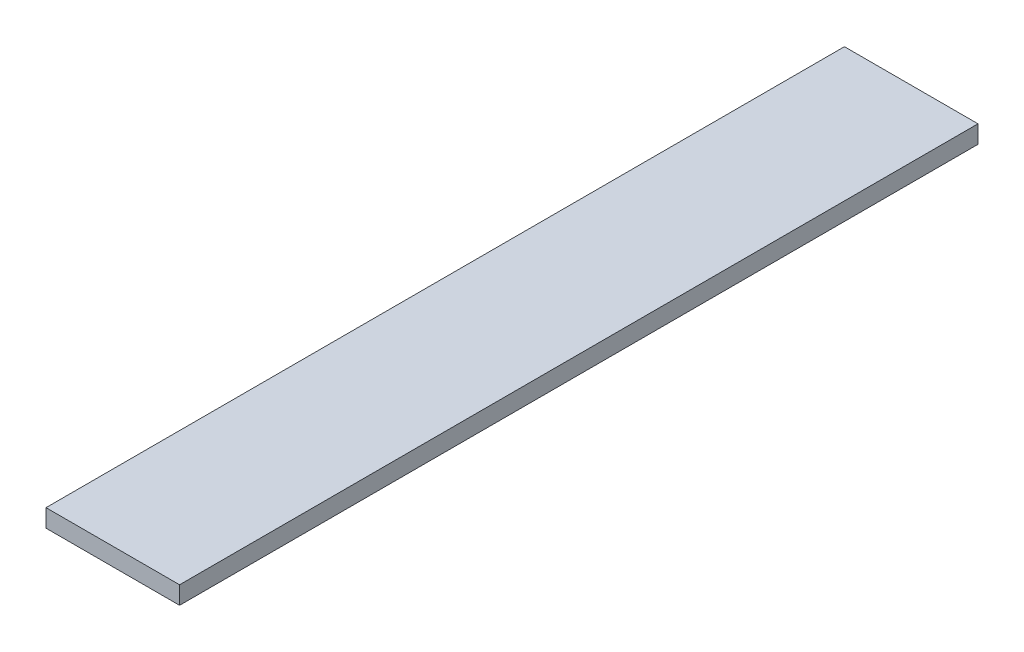
from build123d import *

# Parameters (mm, degrees)
SKETCH1_W           = 285.75
SKETCH1_H           = 1708.15
BOSS_EXTRUDE1_DEPTH = 38.1


with BuildPart() as part:
    # Sketch1 → Boss-Extrude1 (new body)
    with BuildSketch(Plane(origin=(0, 0, 0), x_dir=(1, 0, 0), z_dir=(0, 1, 0))):
        with Locations((142.875, -854.075)):
            Rectangle(SKETCH1_W, SKETCH1_H)
    extrude(amount=BOSS_EXTRUDE1_DEPTH)


solid = part.part
